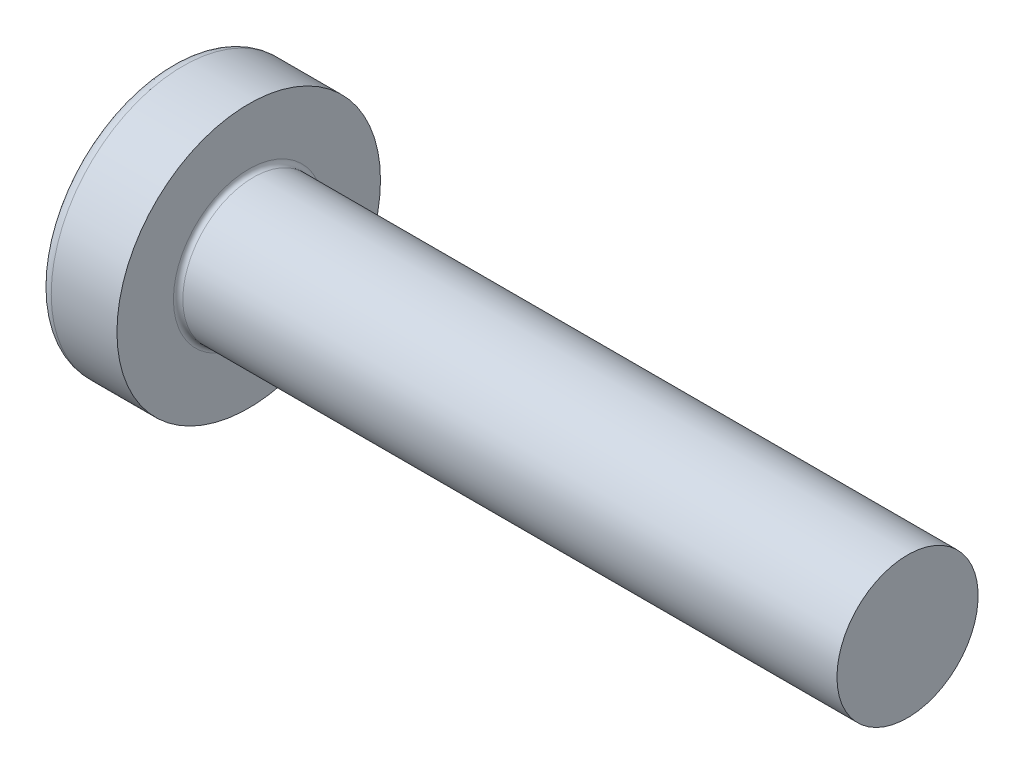
from build123d import *

# Parameters (mm, degrees)
FILLET1_R    = 0.1
SKETCH3_W    = 0.74
SKETCH3_H    = 2.8
SKETCH4_W    = 0.74
SKETCH4_H    = 1.054964664
RECPAT_COUNT = 2
RECPAT_ANGLE = 90


with BuildPart() as part:
    # BodySke → Base-Revolve (revolve)
    with BuildSketch(Plane.XY):
        with BuildLine():
            Line((2.4, 1.5), (2.4, 2.8))
            Line((2.4, 2.8), (1.003501533, 2.8))
            ThreePointArc((1.003501533, 2.8), (0.873295971, 2.76653015), (0.775371599, 2.674418605))
            ThreePointArc((0.775371599, 2.674418605), (0.197753546, 1.392274756), (0, 0))
            Line((0, 0), (16.4, 0))
            Line((16.4, 0), (16.4, 1.5))
            Line((16.4, 1.5), (2.4, 1.5))
        make_face()
    revolve(axis=Axis((-25.4, 0, 0), (1, 0, 0)))

    # Fillet1
    fillet1_edges = [part.edges().sort_by_distance(p)[0] for p in [
        (2.4, -1.5, 0),
    ]]
    fillet(fillet1_edges, radius=FILLET1_R)

    # Sketch3 → Recess section 0
    with BuildSketch(Plane(origin=(0, 0, 0), x_dir=(0, 0, -1), z_dir=(1, 0, 0))):
        Rectangle(SKETCH3_W, SKETCH3_H)
    # Sketch4 → Recess section 1
    with BuildSketch(Plane(origin=(1.75, 0, 0), x_dir=(0, 0, -1), z_dir=(1, 0, 0))):
        Rectangle(SKETCH4_W, SKETCH4_H)
    recess = loft(mode=Mode.SUBTRACT)

    # RecPat: Recess ×2 about axis
    recpat_axis = Axis((0, 0, 0), (1, 0, 0))
    for i in range(1, RECPAT_COUNT):
        add(recess.rotate(recpat_axis, i * RECPAT_ANGLE / (RECPAT_COUNT - 1)), mode=Mode.SUBTRACT)

    # RecCorSke → RecessCore (revolve, cut)
    with BuildSketch(Plane.XY):
        Polygon((0, 0), (0, 0.678371921), (1.75, 0.556), (1.930655351, 0), align=None)
    revolve(axis=Axis((-3.175, 0, 0), (1, 0, 0)), mode=Mode.SUBTRACT)


solid = part.part
